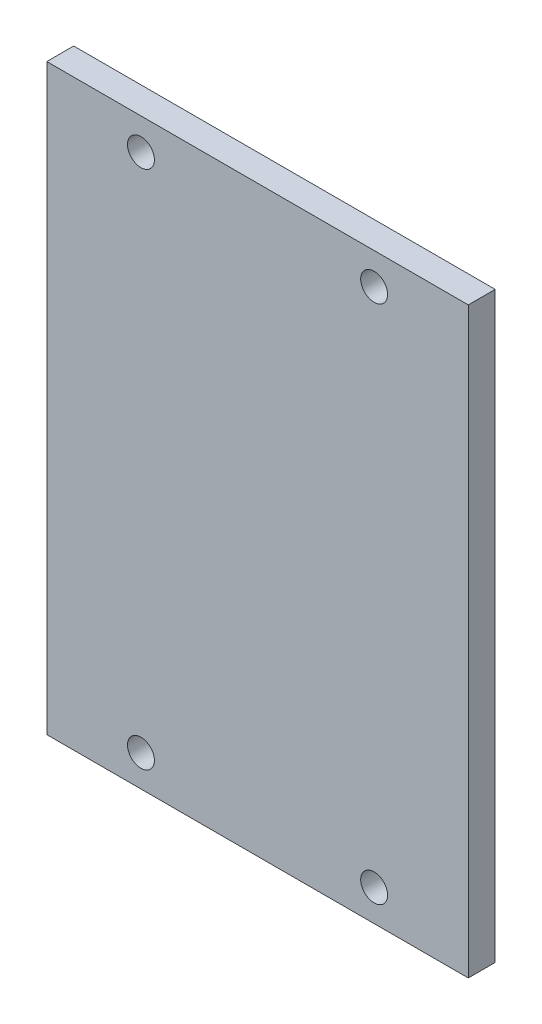
from build123d import *

# Parameters (mm, degrees)
SKETCH1_W                 = 47
SKETCH1_H                 = 65
BOSS_EXTRUDE1_DEPTH       = 3
F_3_0MM_DOWEL_HOLE1_D     = 3
F_3_0MM_DOWEL_HOLE1_DEPTH = 4
F_3_0MM_DOWEL_HOLE1_TIP   = 0.901290929


with BuildPart() as part:
    # Sketch1 → Boss-Extrude1 (new body)
    with BuildSketch(Plane.XY):
        Rectangle(SKETCH1_W, SKETCH1_H)
    extrude(amount=BOSS_EXTRUDE1_DEPTH)

    # Ø3.0mm Dowel Hole1
    with Locations(Plane.XY.offset(3)):
        with Locations((-13, -29), (13, -29), (13, 29), (-13, 29)):
            Hole(F_3_0MM_DOWEL_HOLE1_D / 2, depth=F_3_0MM_DOWEL_HOLE1_DEPTH)
            with Locations((0, 0, -(F_3_0MM_DOWEL_HOLE1_DEPTH + F_3_0MM_DOWEL_HOLE1_TIP / 2))):  # 118° drill point
                Cone(0, F_3_0MM_DOWEL_HOLE1_D / 2, F_3_0MM_DOWEL_HOLE1_TIP, mode=Mode.SUBTRACT)


solid = part.part
